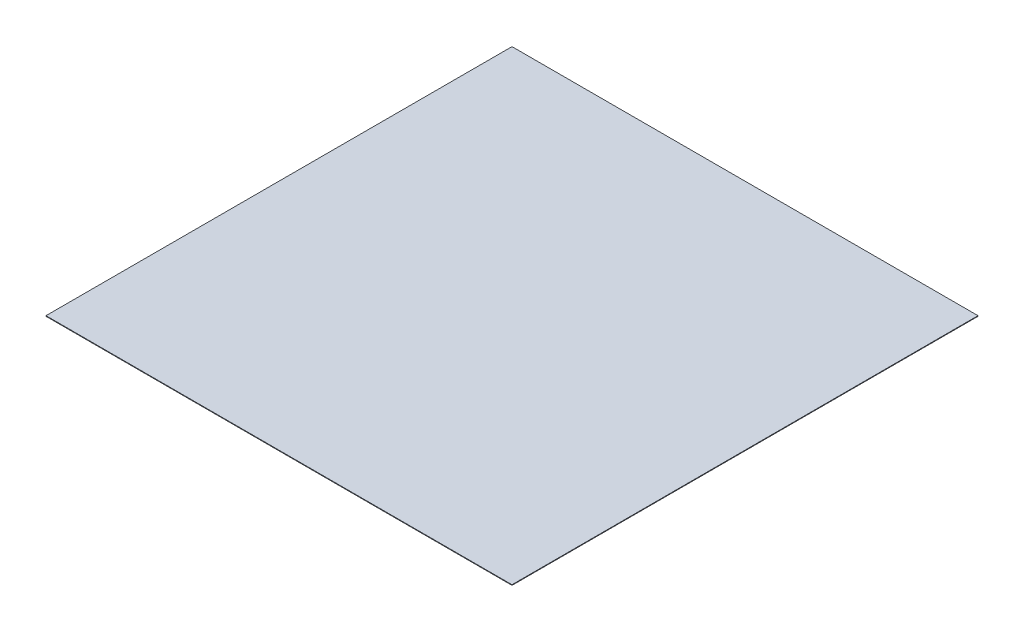
from build123d import *

# Parameters (mm, degrees)
SKETCH1_W           = 80000
SKETCH1_H           = 80000
BOSS_EXTRUDE1_DEPTH = 50


with BuildPart() as part:
    # Sketch1 → Boss-Extrude1 (new body, symmetric)
    with BuildSketch(Plane(origin=(0, 0, 0), x_dir=(1, 0, 0), z_dir=(0, 1, 0))):
        with Locations((-3023.622047244, 7496.062992126)):
            Rectangle(SKETCH1_W, SKETCH1_H)
    extrude(amount=BOSS_EXTRUDE1_DEPTH, both=True)


solid = part.part
